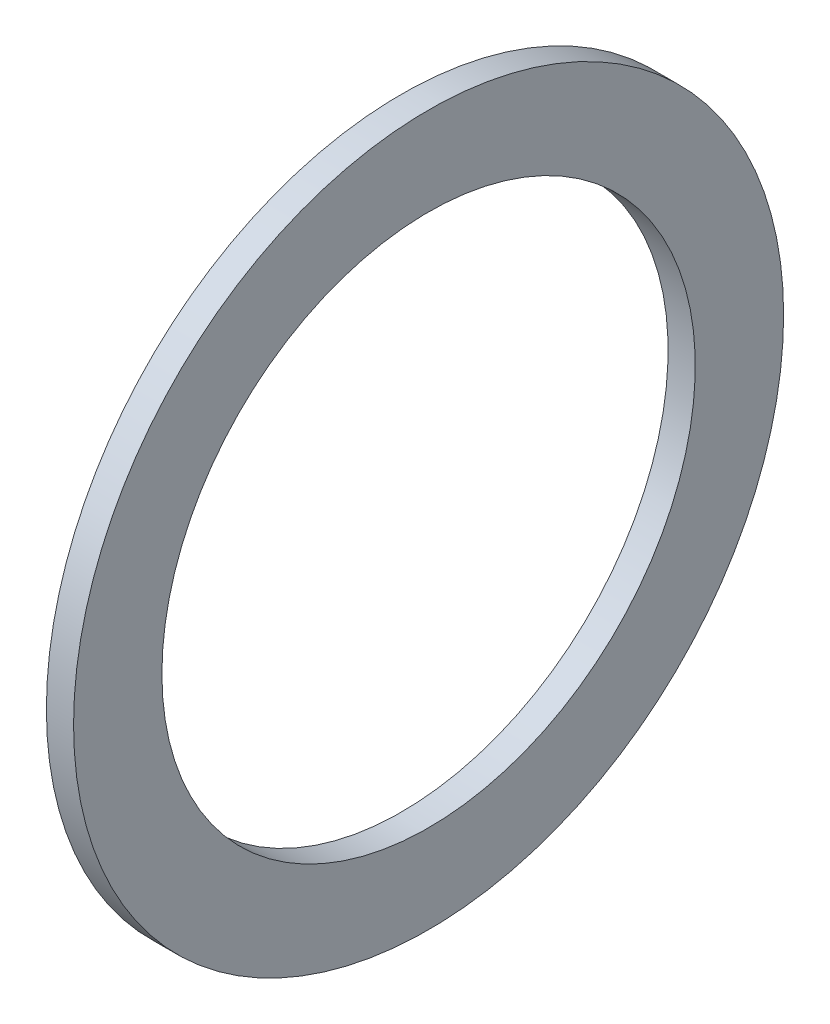
from build123d import *

# Parameters (mm, degrees)
SKETCH1_W = 2.032
SKETCH1_H = 6.604


with BuildPart() as part:
    # Sketch1 → Revolve1 (revolve)
    with BuildSketch(Plane.XY, mode=Mode.PRIVATE) as revolve1_sk:
        with Locations((1.016, -23.241)):
            Rectangle(SKETCH1_W, SKETCH1_H)
    revolve(revolve1_sk.sketch.rotate(Axis((-43.716580756, 0, 0), (1, 0, 0)), 270), axis=Axis((-43.716580756, 0, 0), (1, 0, 0)))  # turned: the seam where the file's is


solid = part.part
